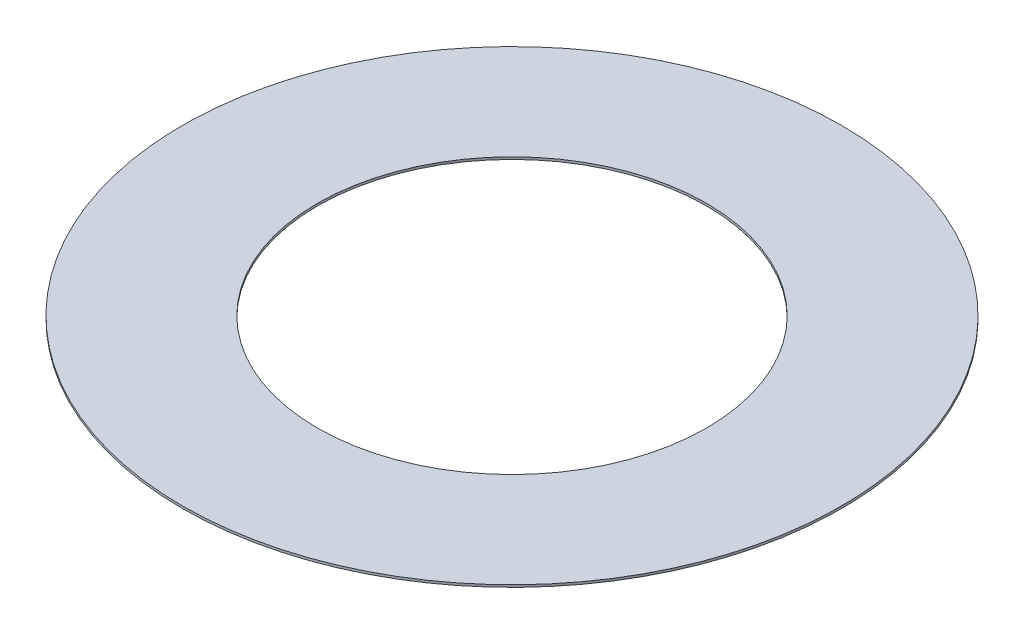
from build123d import *

# Parameters (mm, degrees)
SKETCH1_R           = 25.4
SKETCH1_R_2         = 14.9987
BOSS_EXTRUDE1_DEPTH = 0.0889


with BuildPart() as part:
    # Sketch1 → Boss-Extrude1 (new body, symmetric)
    with BuildSketch(Plane(origin=(0, 0, 0), x_dir=(1, 0, 0), z_dir=(0, 1, 0))):
        Circle(SKETCH1_R)
        Circle(SKETCH1_R_2, mode=Mode.SUBTRACT)
    extrude(amount=BOSS_EXTRUDE1_DEPTH, both=True)


solid = part.part
